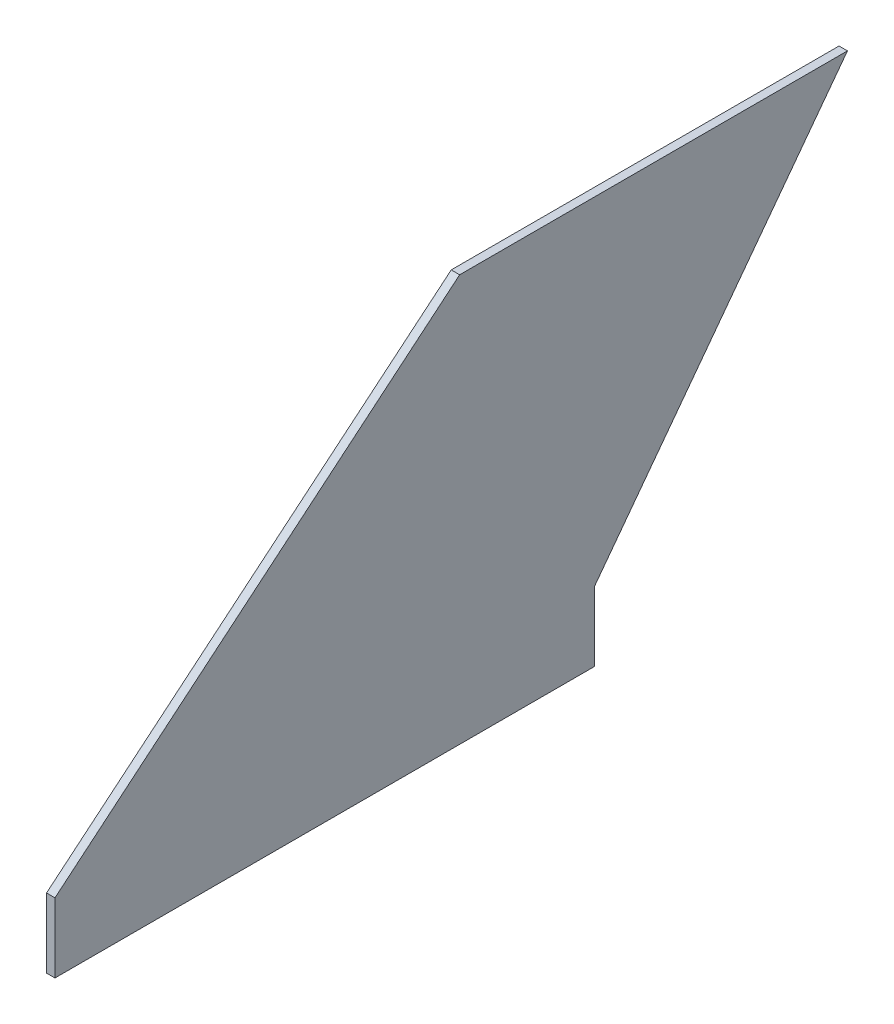
from build123d import *

# Parameters (mm, degrees)
BOSS_EXTRUDE1_DEPTH = 3.175


with BuildPart() as part:
    # Sketch2 → Boss-Extrude1 (new body)
    with BuildSketch(Plane(origin=(0, 0, 0), x_dir=(0, 0, -1), z_dir=(1, 0, 0))):
        Polygon((0, 0), (152.4, 127), (298.45, 127), (203.2, 0), (203.2, -26.1493), (0, -26.1493), align=None)
    extrude(amount=BOSS_EXTRUDE1_DEPTH)


solid = part.part
